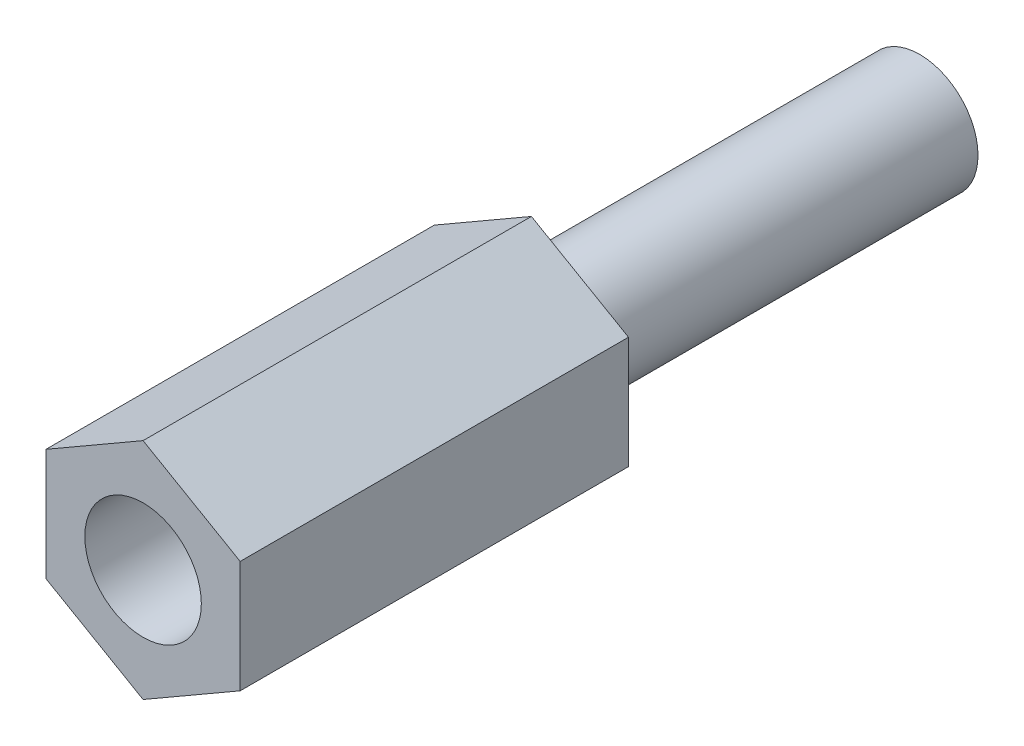
from build123d import *

# Parameters (mm, degrees)
ESQUISSE1_R             = 1.5
BOSS_EXTRU_2_DEPTH      = 10
ESQUISSE3_R             = 1.5
BOSS_EXTRU_3_DEPTH      = 10
BOSS_EXTRU_3_DEPTH_BACK = 2


with BuildPart() as part:
    # Esquisse1 → Boss.-Extru.2 (new body)
    with BuildSketch(Plane.XY):
        Polygon((0, -2.886751346), (2.5, -1.443375673), (2.5, 1.443375673), (0, 2.886751346), (-2.5, 1.443375673), (-2.5, -1.443375673), align=None)
        Circle(ESQUISSE1_R, mode=Mode.SUBTRACT)
    extrude(amount=BOSS_EXTRU_2_DEPTH)

    # Esquisse3 → Boss.-Extru.3 (add, two sides)
    with BuildSketch(Plane(origin=(0, 0, 0), x_dir=(-1, 0, 0), z_dir=(0, 0, -1))) as boss_extru_3_sk:
        Circle(ESQUISSE3_R)
    extrude(amount=BOSS_EXTRU_3_DEPTH)
    extrude(boss_extru_3_sk.sketch, amount=-BOSS_EXTRU_3_DEPTH_BACK)


solid = part.part
